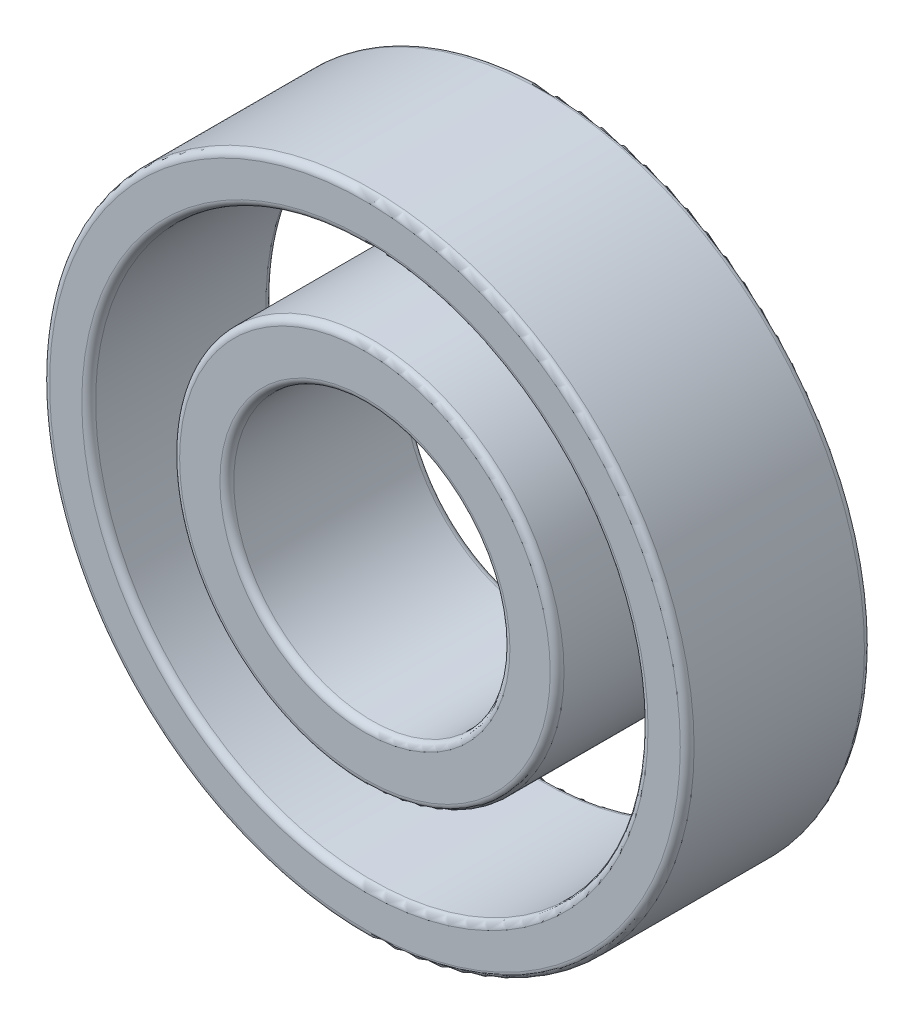
from build123d import *

# Parameters (mm, degrees)
SKETCH1_R             = 14
SKETCH1_R_2           = 12
BOSS_EXTRUDE1_DEPTH   = 8
SKETCH1_R_3           = 8.35
SKETCH1_R_4           = 6
BOSS_EXTRUDE1_2_DEPTH = 8
FILLET1_R             = 0.3
FILLET2_R             = 0.3


with BuildPart() as part:
    # Sketch1 → Boss-Extrude1 (new body)
    with BuildSketch(Plane.XY):
        Circle(SKETCH1_R)
        Circle(SKETCH1_R_2, mode=Mode.SUBTRACT)
    extrude(amount=BOSS_EXTRUDE1_DEPTH)

    # Fillet1
    fillet1_edges = [part.edges().sort_by_distance(p)[0] for p in [
        (-14, 0, 0),
        (-14, 0, 8),
        (-12, 0, 0),
        (-12, 0, 8),
    ]]
    fillet(fillet1_edges, radius=FILLET1_R)


with BuildPart() as body_2:
    # Sketch1 → Boss-Extrude1 2 (new body)
    with BuildSketch(Plane.XY):
        Circle(SKETCH1_R_3)
        Circle(SKETCH1_R_4, mode=Mode.SUBTRACT)
    extrude(amount=BOSS_EXTRUDE1_2_DEPTH)

    # Fillet2
    fillet2_edges = [body_2.edges().sort_by_distance(p)[0] for p in [
        (-6, 0, 0),
        (-6, 0, 8),
        (-8.35, 0, 0),
        (-8.35, 0, 8),
    ]]
    fillet(fillet2_edges, radius=FILLET2_R)


solid = Compound([part.part, body_2.part])
